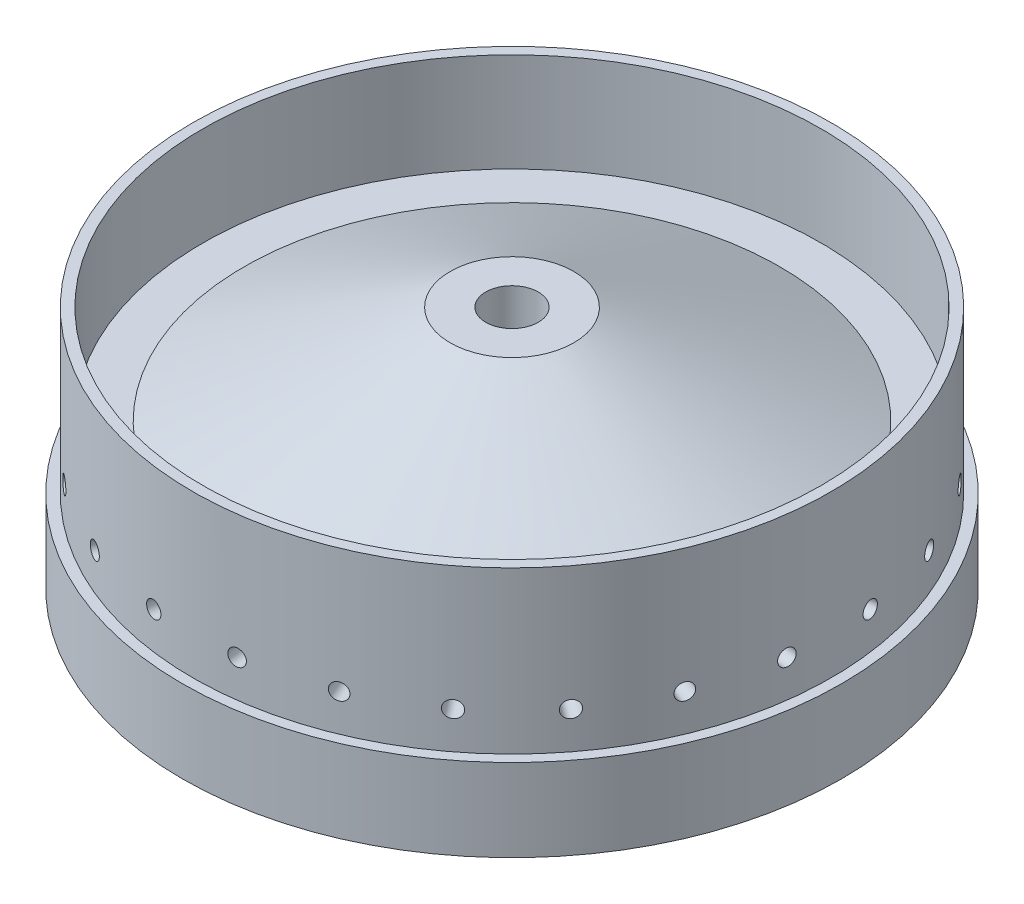
from build123d import *

# Parameters (mm, degrees)
CUT_EXTRUDE2_START    = 25.4
SKETCH3_R             = 101.6
SKETCH3_R_2           = 98.425
CUT_EXTRUDE2_DEPTH    = 50.68875
CIRPATTERN1_COUNT     = 24
BODY_MOVE_COPY1_ANGLE = 90


with BuildPart() as part:
    # Sketch1 → Revolve1 (revolve)
    with BuildSketch(Plane(origin=(0, 0, 0), x_dir=(1, 0, 0), z_dir=(0, 1, 0))):
        with BuildLine():
            add(Edge.make_bspline(
                [(95.25, 0), (95.25, 54.633955198), (8.09625, 59.277841389)],
                knots=[3.141592654, 3.141592654, 3.141592654, 4.627286292, 4.627286292, 4.627286292], degree=2, weights=[1, 0.736545993, 1]))
            Line((95.25, 0), (101.6, 0))
            Line((101.6, 0), (101.6, 59.49315))
            Line((101.6, 59.49315), (101.6, 75.08875))
            Line((101.6, 75.08875), (95.25, 75.08875))
            Line((95.25, 75.08875), (95.25, 44.60875))
            Line((95.25, 44.60875), (82.55, 44.60875))
            Line((82.55, 44.60875), (19.05, 75.08875))
            Line((19.05, 75.08875), (8.09625, 75.08875))
            Line((8.09625, 75.08875), (8.09625, 59.277841389))
        make_face()
    revolve(axis=Axis((0, 0, 0), (0, 0, -1)))

    # Sketch3 → Cut-Extrude2 (cut, through all)
    with BuildSketch(Plane(origin=(0, 0, 0), x_dir=(-1, 0, 0), z_dir=(0, 0, -1)).offset(CUT_EXTRUDE2_START)):
        Circle(SKETCH3_R)
        Circle(SKETCH3_R_2, mode=Mode.SUBTRACT)
    extrude(amount=CUT_EXTRUDE2_DEPTH, mode=Mode.SUBTRACT)

    # Sketch10 → 1/4-20 Tapped Hole1 (revolve, cut)
    with BuildSketch(Plane(origin=(97.582960481, 12.847040469, -36.83), x_dir=(-0.130526192, 0.991444861, 0), z_dir=(0, 0, 1))):
        Polygon((0, 0), (0, 14.233816902), (2.5527, 12.7), (2.5527, 0), align=None)
    f_1_4_20_tapped_hole1 = revolve(axis=Axis((103.87863535, 13.67588179, -36.83), (-0.991444861, -0.130526192, 0)), mode=Mode.SUBTRACT)

    # CirPattern1: 1/4-20 Tapped Hole1 ×24 about axis
    cirpattern1_axis = Axis((0, 0, 0), (0, 0, 1))
    for i in range(1, CIRPATTERN1_COUNT):
        add(f_1_4_20_tapped_hole1.rotate(cirpattern1_axis, i * 360 / CIRPATTERN1_COUNT), mode=Mode.SUBTRACT)


with BuildPart() as part_1:
    # Body-Move/Copy1: moved
    add(part.part.rotate(Axis((0, 0, -37.544375), (1, 0, 0)), BODY_MOVE_COPY1_ANGLE))


solid = part_1.part
